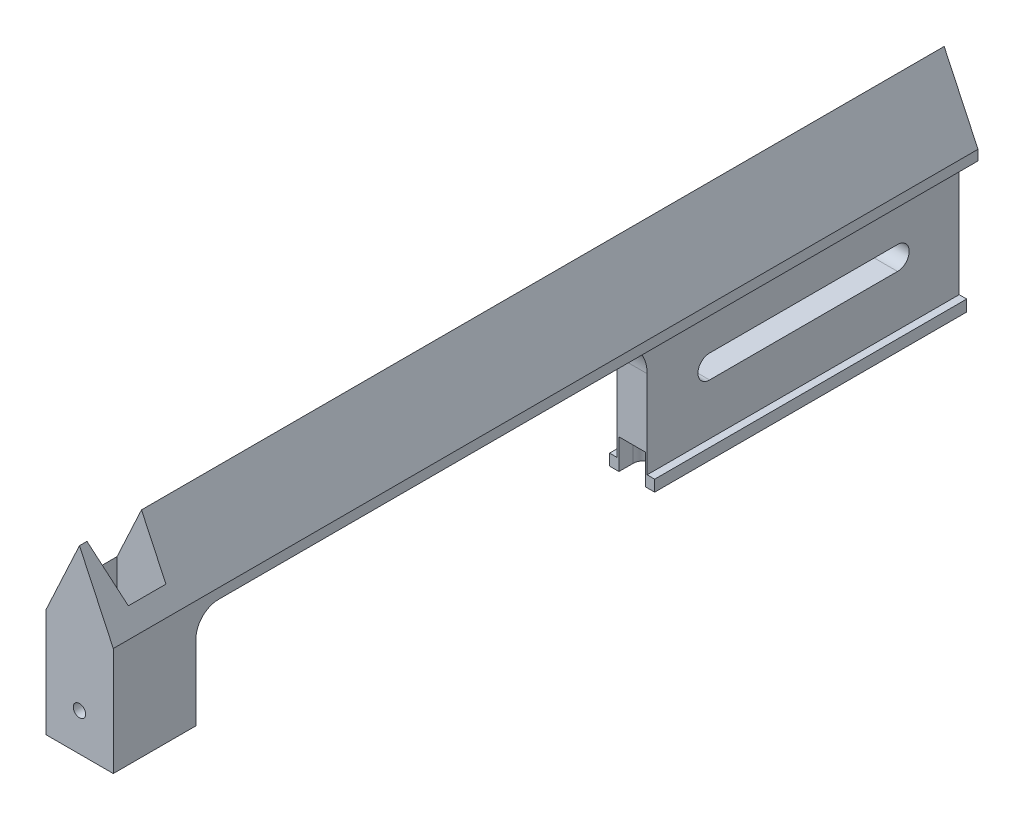
from build123d import *

# Parameters (mm, degrees)
BOSS_EXTRUDE1_DEPTH     = 230
CUT_EXTRUDE2_DEPTH      = 93
SKETCH4_W               = 125
SKETCH4_H               = 36.3
CUT_EXTRUDE3_DEPTH      = 18.9
FILLET3_R               = 10
FILLET4_R               = 6
SKETCH5_W               = 22
SKETCH5_H               = 10.18
CUT_EXTRUDE4_DEPTH      = 18.9
CUT_EXTRUDE5_REACH      = 14.9
CUT_EXTRUDE6_REACH      = 232
SKETCH7_R               = 1.65
CUT_EXTRUDE7_DEPTH      = 49
SKETCH9_W               = 3
SKETCH9_H               = 129.384798753
CUT_EXTRUDE8_DEPTH      = 1
CUT_EXTRUDE8_DEPTH_BACK = 5
SKETCH10_W              = 7
SKETCH10_H              = 13.446036232
CUT_EXTRUDE9_DEPTH      = 8
FILLET5_R               = 3


with BuildPart() as part:
    # Sketch1 → Boss-Extrude1 (new body)
    with BuildSketch(Plane.XY):
        Polygon((0, 0), (-8.900488428, -19.193232029), (-8.900488428, -58.18), (8.999511572, -58.18), (8.999511572, -19.193232029), align=None)
    extrude(amount=BOSS_EXTRUDE1_DEPTH)

    # Sketch3 → Cut-Extrude2 (cut)
    with BuildSketch(Plane(origin=(0, 0, 0), x_dir=(-1, 0, 0), z_dir=(0, 0, -1))):
        Polygon((-6, -58.18), (-6, -55.18), (-4, -55.18), (-4, -21.88), (-8.999511572, -21.88), (-8.999511572, -58.18), align=None)
        Polygon((6, -55.18), (4, -55.18), (4, -21.88), (8.999511572, -21.88), (8.999511572, -58.18), (6, -58.18), align=None)
    extrude(amount=-CUT_EXTRUDE2_DEPTH, mode=Mode.SUBTRACT)

    # Sketch4 → Cut-Extrude3 (cut, through all)
    with BuildSketch(Plane.ZY.offset(8.900488428)):
        with Locations((145.5, -40.03)):
            Rectangle(SKETCH4_W, SKETCH4_H)
    extrude(amount=-CUT_EXTRUDE3_DEPTH, mode=Mode.SUBTRACT)

    # Fillet3
    fillet3_edges = [part.edges().sort_by_distance(p)[0] for p in [
        (0, -21.88, 83),
    ]]
    fillet(fillet3_edges, radius=FILLET3_R)

    # Fillet4
    fillet4_edges = [part.edges().sort_by_distance(p)[0] for p in [
        (0.049511572, -21.88, 208),
    ]]
    fillet(fillet4_edges, radius=FILLET4_R)

    # Sketch5 → Cut-Extrude4 (cut, through all)
    with BuildSketch(Plane(origin=(8.999511572, 0, 0), x_dir=(0, 0, -1), z_dir=(1, 0, 0))):
        with Locations((-219, -53.09)):
            Rectangle(SKETCH5_W, SKETCH5_H)
    extrude(amount=-CUT_EXTRUDE4_DEPTH, mode=Mode.SUBTRACT)

    # Sketch6 → Cut-Extrude5 (cut, up to next)
    with BuildSketch(Plane(origin=(4, 0, 0), x_dir=(0, 0, -1), z_dir=(1, 0, 0)), mode=Mode.PRIVATE) as cut_extrude5_sk1:
        with BuildLine():
            Line((-66.4, -35.43), (-16.4, -35.43))
            ThreePointArc((-16.4, -35.43), (-13.3, -38.53), (-16.4, -41.63))
            Line((-16.4, -41.63), (-66.4, -41.63))
            ThreePointArc((-66.4, -41.63), (-69.5, -38.53), (-66.4, -35.43))
        make_face()
    cut_extrude5_tool1 = extrude(cut_extrude5_sk1.sketch, amount=-CUT_EXTRUDE5_REACH, mode=Mode.PRIVATE) & part.part
    add(cut_extrude5_tool1.solids().sort_by_distance((4, -38.53, 41.4))[0], mode=Mode.SUBTRACT)

    # Sketch7 → Cut-Extrude6 (cut, up to next)
    with BuildSketch(Plane.XY.offset(230), mode=Mode.PRIVATE) as cut_extrude6_sk1:
        with Locations((0, -38)):
            Circle(SKETCH7_R)
    cut_extrude6_tool1 = extrude(cut_extrude6_sk1.sketch, amount=-CUT_EXTRUDE6_REACH, mode=Mode.PRIVATE) & part.part
    add(cut_extrude6_tool1.solids().sort_by_distance((0, -38, 230))[0], mode=Mode.SUBTRACT)

    # Sketch8 → Cut-Extrude7 (cut, through all)
    with BuildSketch(Plane.XZ.offset(48)):
        Polygon((0, 228), (-6.5, 223.5), (-6.5, 213.5), (6.5, 213.5), (6.5, 223.5), align=None)
    extrude(amount=-CUT_EXTRUDE7_DEPTH, mode=Mode.SUBTRACT)

    # Sketch9 → Cut-Extrude8 (cut, two sides)
    with BuildSketch(Plane.XZ.offset(58.18)) as cut_extrude8_sk:
        with Locations((0, 45.686714954)):
            Rectangle(SKETCH9_W, SKETCH9_H)
    extrude(amount=CUT_EXTRUDE8_DEPTH, mode=Mode.SUBTRACT)
    extrude(cut_extrude8_sk.sketch, amount=-CUT_EXTRUDE8_DEPTH_BACK, mode=Mode.SUBTRACT)

    # Sketch10 → Cut-Extrude9 (cut)
    with BuildSketch(Plane.XZ.offset(58.18)):
        with Locations((0, 83)):
            Rectangle(SKETCH10_W, SKETCH10_H)
    extrude(amount=-CUT_EXTRUDE9_DEPTH, mode=Mode.SUBTRACT)

    # Fillet5
    fillet5_edges = [part.edges().sort_by_distance(p)[0] for p in [
        (3.5, -54.18, 76.276981884),
        (-3.5, -54.18, 76.276981884),
    ]]
    fillet(fillet5_edges, radius=FILLET5_R)


solid = part.part
